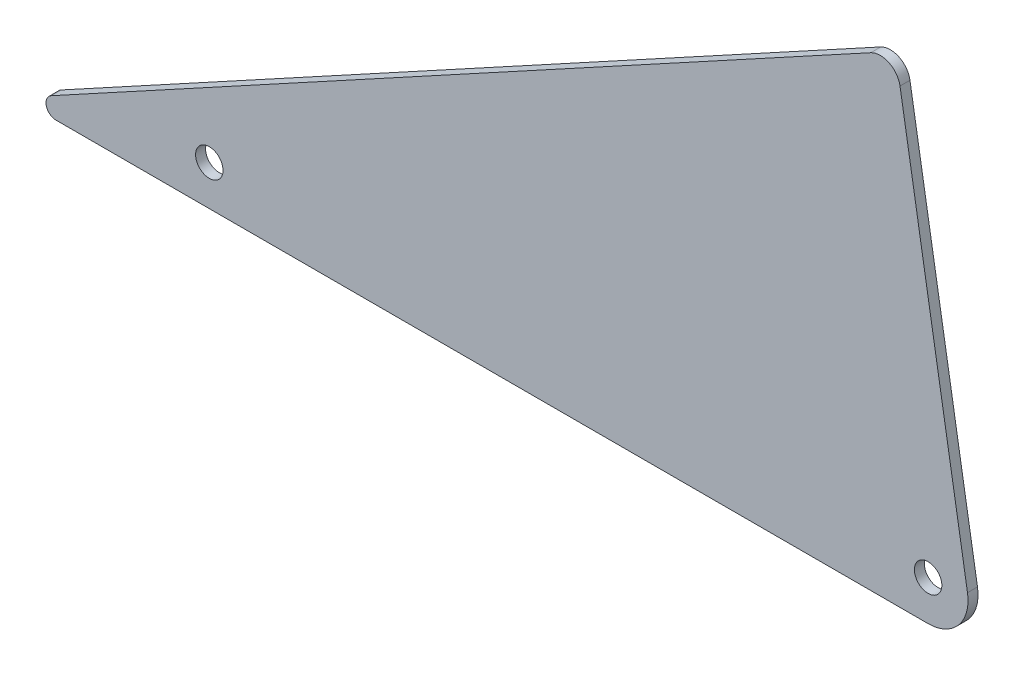
from build123d import *

# Parameters (mm, degrees)
SKETCH1_R           = 2.1828125
BOSS_EXTRUDE1_DEPTH = 0.79375
FILLET1_R           = 6.35
FILLET2_R           = 3.175
FILLET3_R           = 1.5875


with BuildPart() as part:
    # Sketch1 → Boss-Extrude1 (new body, symmetric)
    with BuildSketch(Plane.XY):
        Polygon((0, 0), (-152.4, 0), (-12.7, 76.2), align=None)
        with Locations((-7.495923678, 6.35)):
            Circle(SKETCH1_R, mode=Mode.SUBTRACT)
        with Locations((-121.795923678, 6.35)):
            Circle(SKETCH1_R, mode=Mode.SUBTRACT)
    extrude(amount=BOSS_EXTRUDE1_DEPTH, both=True)

    # Fillet1
    fillet1_edges = [part.edges().sort_by_distance(p)[0] for p in [
        (0, 0, 0),
    ]]
    fillet(fillet1_edges, radius=FILLET1_R)

    # Fillet2
    fillet2_edges = [part.edges().sort_by_distance(p)[0] for p in [
        (-12.7, 76.2, 0),
    ]]
    fillet(fillet2_edges, radius=FILLET2_R)

    # Fillet3
    fillet3_edges = [part.edges().sort_by_distance(p)[0] for p in [
        (-152.4, 0, 0),
    ]]
    fillet(fillet3_edges, radius=FILLET3_R)


solid = part.part
